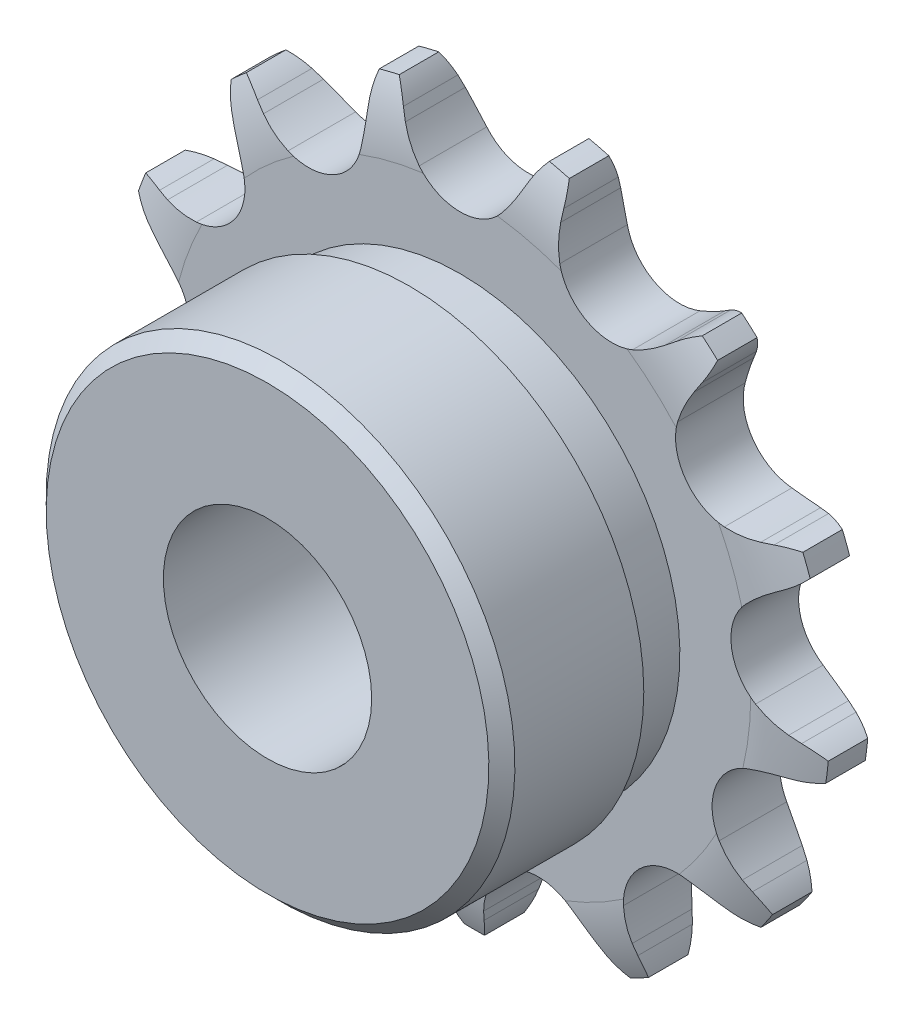
from build123d import *

# Parameters (mm, degrees)
CUT_EXTRUDE1_DEPTH      = 20.801374208
CIRPATTERN1_COUNT       = 13
BOSS_EXTRUDE1_START     = 1.3
SKETCH2_R               = 9
BOSS_EXTRUDE1_DEPTH     = 7.4
CUT_EXTRUDE2_DEPTH      = 22.538810241
CUT_EXTRUDE2_DEPTH_BACK = 22.538810241
SKETCH3_R               = 4
SKETCH4_W               = 1.95
SKETCH4_H               = 5.53573405
CUT_EXTRUDE3_DEPTH      = 22.538810241
CUT_EXTRUDE3_DEPTH_BACK = 22.538810241
SKETCH5_OUTSIDE_W       = 37.868
SKETCH5_OUTSIDE_H       = 37.667
SKETCH5_OUTSIDE_R       = 13.65


with BuildPart() as part:
    # Sketch1 → Revolve1 (revolve)
    with BuildSketch(Plane(origin=(0, 0, 0), x_dir=(0, 0, -1), z_dir=(1, 0, 0))):
        with BuildLine():
            Line((1.3, 0), (-1.3, 0))
            Line((-1.3, 0), (-1.3, 11.159006235))
            ThreePointArc((-1.3, 11.159006235), (-1.122370651, 12.608143909), (-0.6, 13.971478457))
            Line((-0.6, 13.971478457), (0.6, 13.971478457))
            ThreePointArc((0.6, 13.971478457), (1.122370651, 12.608143909), (1.3, 11.159006235))
            Line((1.3, 11.159006235), (1.3, 0))
        make_face()
    revolve(axis=Axis((0, 0, -1.3), (0, 0, 1)))

    # Sketch0 → Cut-Extrude1 (cut, symmetric)
    with BuildSketch(Plane.XY):
        with BuildLine():
            Line((5.393631525, -11.70370877), (5.128672985, -11.385348162))
            ThreePointArc((5.128672985, -11.385348162), (4.69972071, -10.928437472), (4.219361457, -10.525917383))
            ThreePointArc((4.219361457, -10.525917383), (2.509857588, -10.182892521), (1.155578688, -11.281072013))
            ThreePointArc((1.155578688, -11.281072013), (0.917302106, -11.860719926), (0.749820714, -12.464638312))
            Line((0.749820714, -12.464638312), (0.66316113, -12.869665004))
            ThreePointArc((0.66316113, -12.869665004), (-0.785825649, -14.972274137), (-3.297106699, -15.434870445))
            ThreePointArc((-3.297106699, -15.434870445), (3.777142247, -15.324468496), (10.092384947, -12.134657157))
            ThreePointArc((10.092384947, -12.134657157), (7.653776786, -12.892098964), (5.393631525, -11.70370877))
        make_face()
    cut_extrude1 = extrude(amount=CUT_EXTRUDE1_DEPTH, both=True, mode=Mode.SUBTRACT)

    # CirPattern1: Cut-Extrude1 ×13 about axis
    cirpattern1_axis = Axis((0, 0, 0), (0, 0, 1))
    for i in range(1, CIRPATTERN1_COUNT):
        add(cut_extrude1.rotate(cirpattern1_axis, i * 360 / CIRPATTERN1_COUNT), mode=Mode.SUBTRACT)

    # Sketch2 → Boss-Extrude1 (add)
    with BuildSketch(Plane.XY.offset(BOSS_EXTRUDE1_START)):
        with Locations(Location((0, 0, 0), (0, 0, 270))):
            Circle(SKETCH2_R)
    extrude(amount=BOSS_EXTRUDE1_DEPTH)

    # Sketch3 → Cut-Extrude2 (cut, two sides: drawn at the far end of the back side and taken through both)
    with BuildSketch(Plane.XY.offset(-CUT_EXTRUDE2_DEPTH_BACK)):
        Circle(SKETCH3_R)
    extrude(amount=CUT_EXTRUDE2_DEPTH + CUT_EXTRUDE2_DEPTH_BACK, mode=Mode.SUBTRACT)

    # Sketch4 → Cut-Revolve1 (revolve, cut)
    with BuildSketch(Plane(origin=(0, 0, 0), x_dir=(0, 0, -1), z_dir=(1, 0, 0))):
        Polygon((-8.7, 9), (-8.7, 8.5), (-8.2, 9), align=None)
        with Locations((-2.275, 11.203611432)):
            Rectangle(SKETCH4_W, SKETCH4_H)
    revolve(axis=Axis((0, 0, -1.3), (0, 0, 1)), mode=Mode.SUBTRACT)

    # Sketch5 outside → Cut-Extrude3 (cut, two sides: drawn at the far end of the back side and taken through both)
    with BuildSketch(Plane.XY.offset(-CUT_EXTRUDE3_DEPTH_BACK)):
        with Locations((0, -0.1785)):
            Rectangle(SKETCH5_OUTSIDE_W, SKETCH5_OUTSIDE_H)
        Circle(SKETCH5_OUTSIDE_R, mode=Mode.SUBTRACT)
    extrude(amount=CUT_EXTRUDE3_DEPTH + CUT_EXTRUDE3_DEPTH_BACK, mode=Mode.SUBTRACT)


solid = part.part
